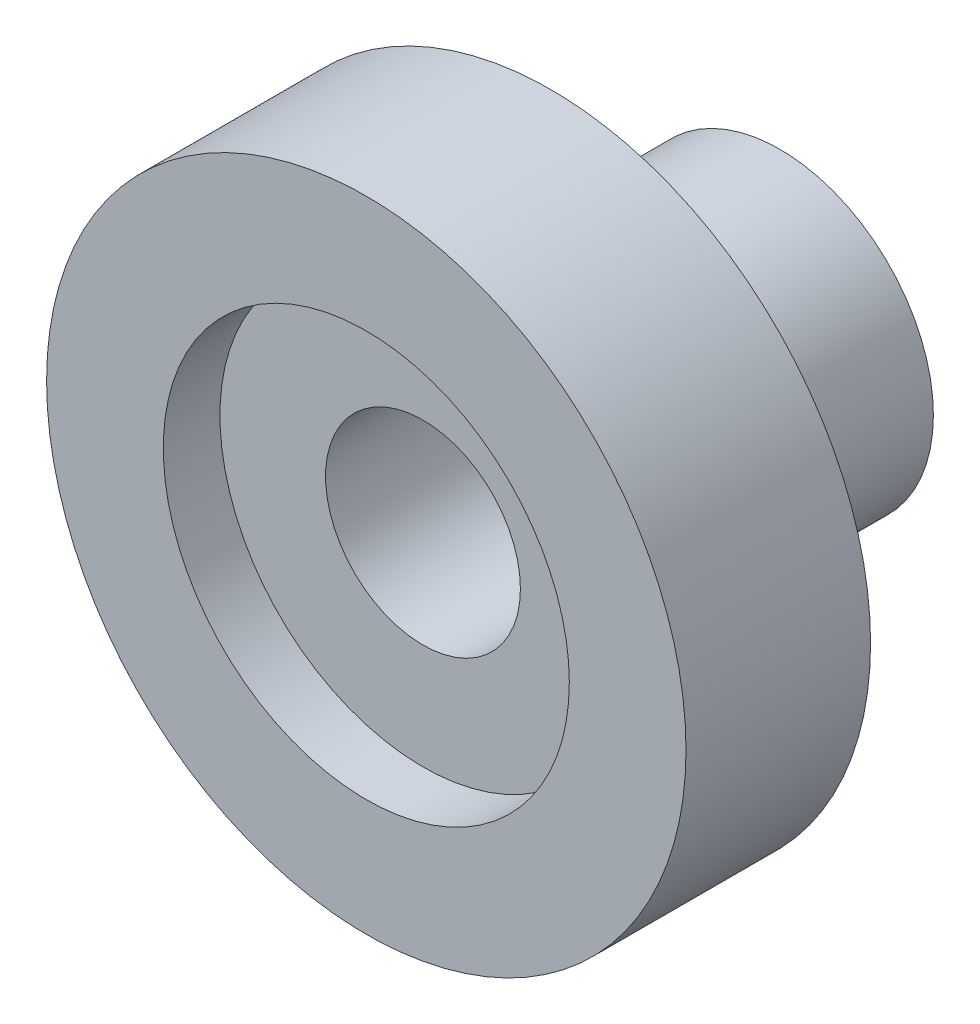
from build123d import *

# Parameters (mm, degrees)
SKETCH1_R           = 6
SKETCH1_R_2         = 3.81
BOSS_EXTRUDE1_DEPTH = 18.9352
SKETCH2_R           = 8.374556064
CUT_EXTRUDE1_DEPTH  = 4.9784
SKETCH3_R           = 12.5
SKETCH3_R_2         = 7.9375
BOSS_EXTRUDE2_DEPTH = 3.216
SKETCH4_R           = 12.5
SKETCH4_R_2         = 6
BOSS_EXTRUDE3_DEPTH = 5
SKETCH6_R           = 16.299609394
CUT_EXTRUDE2_DEPTH  = 1


with BuildPart() as part:
    # Sketch1 → Boss-Extrude1 (new body)
    with BuildSketch(Plane.XY):
        Circle(SKETCH1_R)
        Circle(SKETCH1_R_2, mode=Mode.SUBTRACT)
    extrude(amount=BOSS_EXTRUDE1_DEPTH)

    # Sketch2 → Cut-Extrude1 (cut)
    with BuildSketch(Plane.XY.offset(18.9352)):
        Circle(SKETCH2_R)
    extrude(amount=-CUT_EXTRUDE1_DEPTH, mode=Mode.SUBTRACT)



with BuildPart() as body_2:
    # Sketch3 → Boss-Extrude2 (new body)
    with BuildSketch(Plane.XY.offset(13.9568)):
        Circle(SKETCH3_R)
        Circle(SKETCH3_R_2, mode=Mode.SUBTRACT)
    extrude(amount=BOSS_EXTRUDE2_DEPTH)


with BuildPart() as part_1:
    add(part.part)

    add(body_2.part)  # Boss-Extrude3 merges body 2
    # Sketch4 → Boss-Extrude3 (add)
    with BuildSketch(Plane(origin=(0, 0, 13.9568), x_dir=(-1, 0, 0), z_dir=(0, 0, -1))):
        Circle(SKETCH4_R)
        Circle(SKETCH4_R_2, mode=Mode.SUBTRACT)
    extrude(amount=BOSS_EXTRUDE3_DEPTH)

    # Sketch6 → Cut-Extrude2 (cut)
    with BuildSketch(Plane.XY.offset(17.1728)):
        Circle(SKETCH6_R)
    extrude(amount=-CUT_EXTRUDE2_DEPTH, mode=Mode.SUBTRACT)


solid = part_1.part
